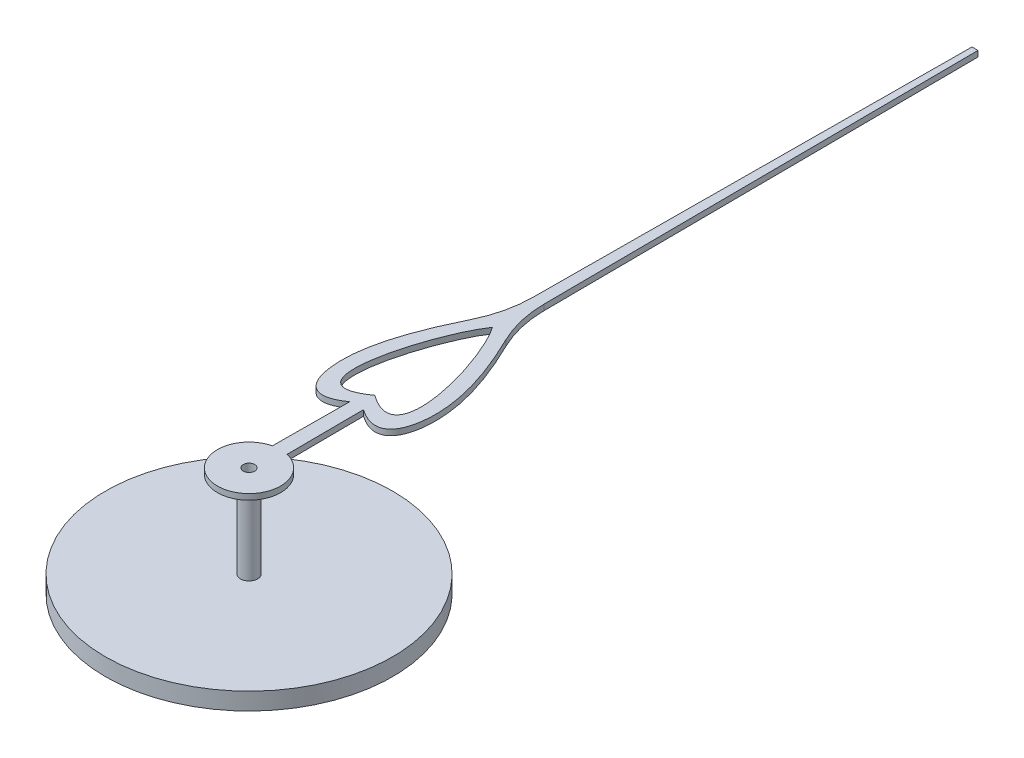
from build123d import *

# Parameters (mm, degrees)
BOSS_EXTRUDE1_DEPTH = 0.1
SKETCH2_R           = 0.15
BOSS_EXTRUDE2_DEPTH = 1.5
SKETCH3_R           = 2.5
BOSS_EXTRUDE3_DEPTH = 0.3
SKETCH4_R           = 0.1
CUT_EXTRUDE1_DEPTH  = 2.9


with BuildPart() as part:
    # Sketch1 → Boss-Extrude1 (new body)
    with BuildSketch(Plane(origin=(0, 0, 0), x_dir=(1, 0, 0), z_dir=(0, 1, 0))):
        with BuildLine():
            Line((-0.127906747, 0.534920428), (-0.119541068, 1.873429083))
            add(Edge.make_bspline(
                [(-0.119541068, 1.873429083), (-0.641060696, 1.506237283), (-1.004261291, 2.385988304), (-0.624353855, 3.513359347), (-0.302826258, 4.171285989)],
                knots=[0, 0, 0, 0, 0.462172684, 0.924345367, 0.924345367, 0.924345367, 0.924345367], degree=3))
            ThreePointArc((-0.302826258, 4.171285989), (-0.152583372, 4.592680906), (-0.099769187, 5.036930007))
            Line((-0.099769187, 5.036930007), (-0.052260994, 12.638240889))
            Line((-0.052260994, 12.638240889), (0.052260994, 12.638240889))
            Line((0.052260994, 12.638240889), (0.099769187, 5.036930007))
            ThreePointArc((0.099769187, 5.036930007), (0.152583372, 4.592680906), (0.302826258, 4.171285989))
            add(Edge.make_bspline(
                [(0.119541068, 1.873429083), (0.641060696, 1.506237283), (1.004261291, 2.385988304), (0.624353855, 3.513359347), (0.302826258, 4.171285989)],
                knots=[0, 0, 0, 0, 0.462172684, 0.924345367, 0.924345367, 0.924345367, 0.924345367], degree=3))
            Line((0.119541068, 1.873429083), (0.127906747, 0.534920428))
            ThreePointArc((0.127906747, 0.534920428), (0, -0.55), (-0.127906747, 0.534920428))
        make_face()
        with BuildLine():
            add(Edge.make_bspline(
                [(0, 2.187874242), (-1.052874031, 1.436460782), (-0.435783261, 3.612960551), (0, 4.238807322)],
                knots=[0, 0, 0, 0, 1, 1, 1, 1], degree=3))
            add(Edge.make_bspline(
                [(0, 2.187874242), (1.052874031, 1.436460782), (0.435783261, 3.612960551), (0, 4.238807322)],
                knots=[0, 0, 0, 0, 1, 1, 1, 1], degree=3))
        make_face(mode=Mode.SUBTRACT)
    extrude(amount=BOSS_EXTRUDE1_DEPTH)

    # Sketch2 → Boss-Extrude2 (add)
    with BuildSketch(Plane.XZ):
        Circle(SKETCH2_R)
    extrude(amount=BOSS_EXTRUDE2_DEPTH)

    # Sketch3 → Boss-Extrude3 (add)
    with BuildSketch(Plane.XZ.offset(1.5)):
        Circle(SKETCH3_R)
    extrude(amount=BOSS_EXTRUDE3_DEPTH)

    # Sketch4 → Cut-Extrude1 (cut, through all)
    with BuildSketch(Plane(origin=(0, 0.1, 0), x_dir=(1, 0, 0), z_dir=(0, 1, 0))):
        Circle(SKETCH4_R)
    extrude(amount=-CUT_EXTRUDE1_DEPTH, mode=Mode.SUBTRACT)


solid = part.part
